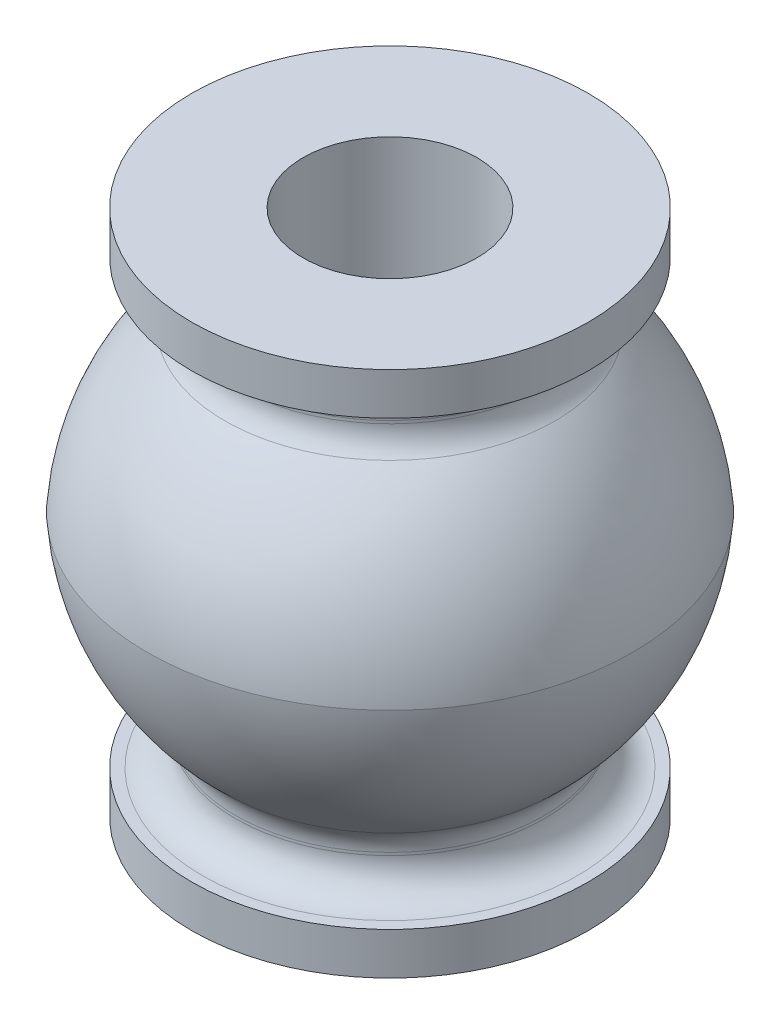
from build123d import *

# Parameters (mm, degrees)
FILLET1_R = 1


with BuildPart() as part:
    # Sketch2 → Revolve1 (revolve)
    with BuildSketch(Plane.XY):
        with BuildLine():
            Line((2.64, 8), (6.02, 8))
            Line((6.02, 8), (6.02, 6.72))
            Line((6.02, 6.72), (4.69, 6.72))
            Line((4.69, 6.72), (4.69, 5.18))
            ThreePointArc((4.69, 5.18), (6.564565369, 2.86579064), (7.375, 0))
            ThreePointArc((7.375, 0), (6.564565369, -2.86579064), (4.69, -5.18))
            Line((4.69, -5.18), (4.69, -6.72))
            Line((4.69, -6.72), (6.02, -6.72))
            Line((6.02, -6.72), (6.02, -8))
            Line((6.02, -8), (2.64, -8))
            Line((2.64, -8), (2.64, -4.005156913))
            Line((2.64, -4.005156913), (3.725560411, -4.005156913))
            ThreePointArc((3.725560411, -4.005156913), (5.189254963, -2.215549668), (5.849887614, 0))
            ThreePointArc((5.849887614, 0), (5.189254963, 2.215549668), (3.725560411, 4.005156913))
            Line((3.725560411, 4.005156913), (2.64, 4.005156913))
            Line((2.64, 4.005156913), (2.64, 8))
        make_face()
    revolve(axis=Axis((0, -8, 0), (0, 1, 0)))

    # Fillet1
    fillet1_edges = [part.edges().sort_by_distance(p)[0] for p in [
        (-4.69, -6.72, 0),
        (-4.69, -5.18, 0),
        (-4.69, 5.18, 0),
        (-4.69, 6.72, 0),
    ]]
    fillet(fillet1_edges, radius=FILLET1_R)


solid = part.part
